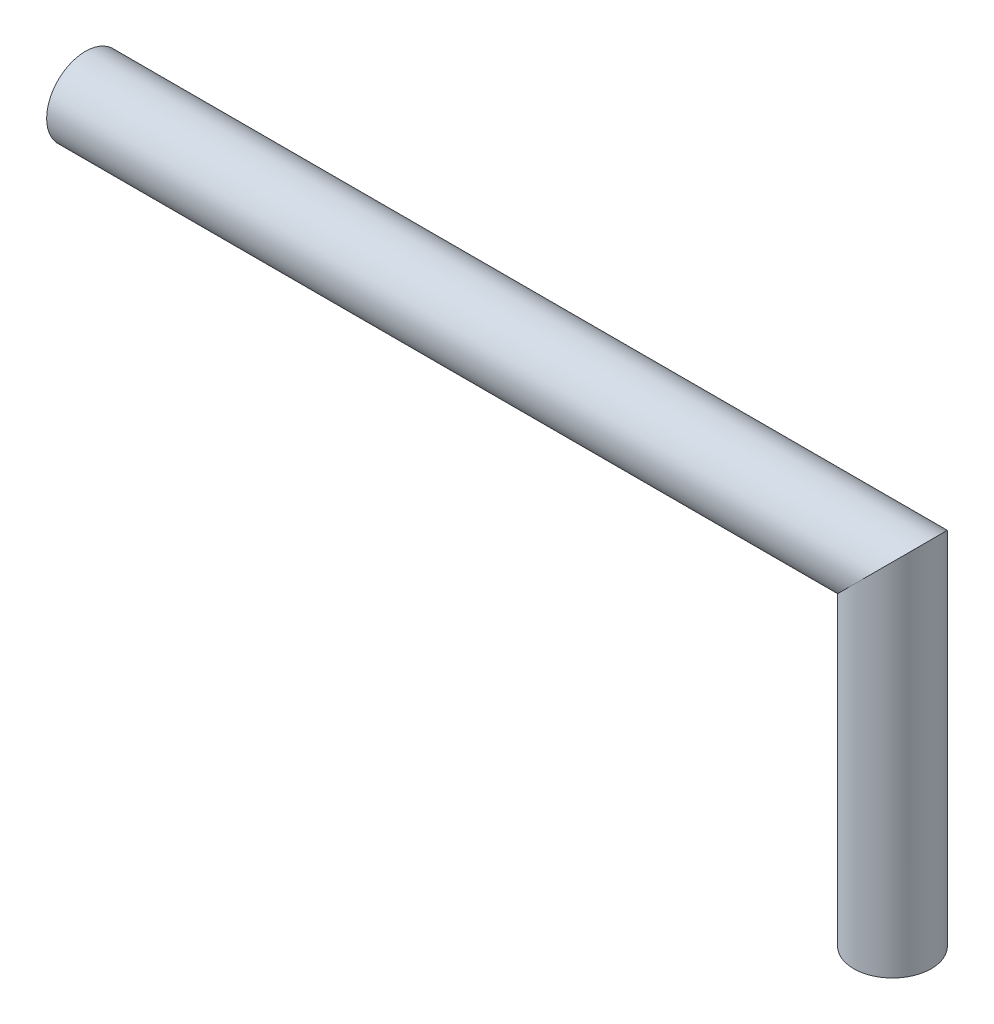
from build123d import *

# Parameters (mm, degrees)
SWEEP2_PROFILE_R = 3.556


with BuildPart() as part:
    # Sweep2: sweep along a path in Sketch1
    with BuildLine(Plane.XY) as sweep2_path:
        Line((-73.927538071, 0), (0, 0))
        Line((0, 0), (0, -30.492893401))
    # Sweep2 profile (on start of the path) → Sweep2 (sweep)
    with BuildSketch(Plane(origin=(-73.927538071, 0, 0), x_dir=(0, 0, 1), z_dir=(1, 0, 0))):
        Circle(SWEEP2_PROFILE_R)
    sweep(path=sweep2_path.line, transition=Transition.RIGHT)


solid = part.part
